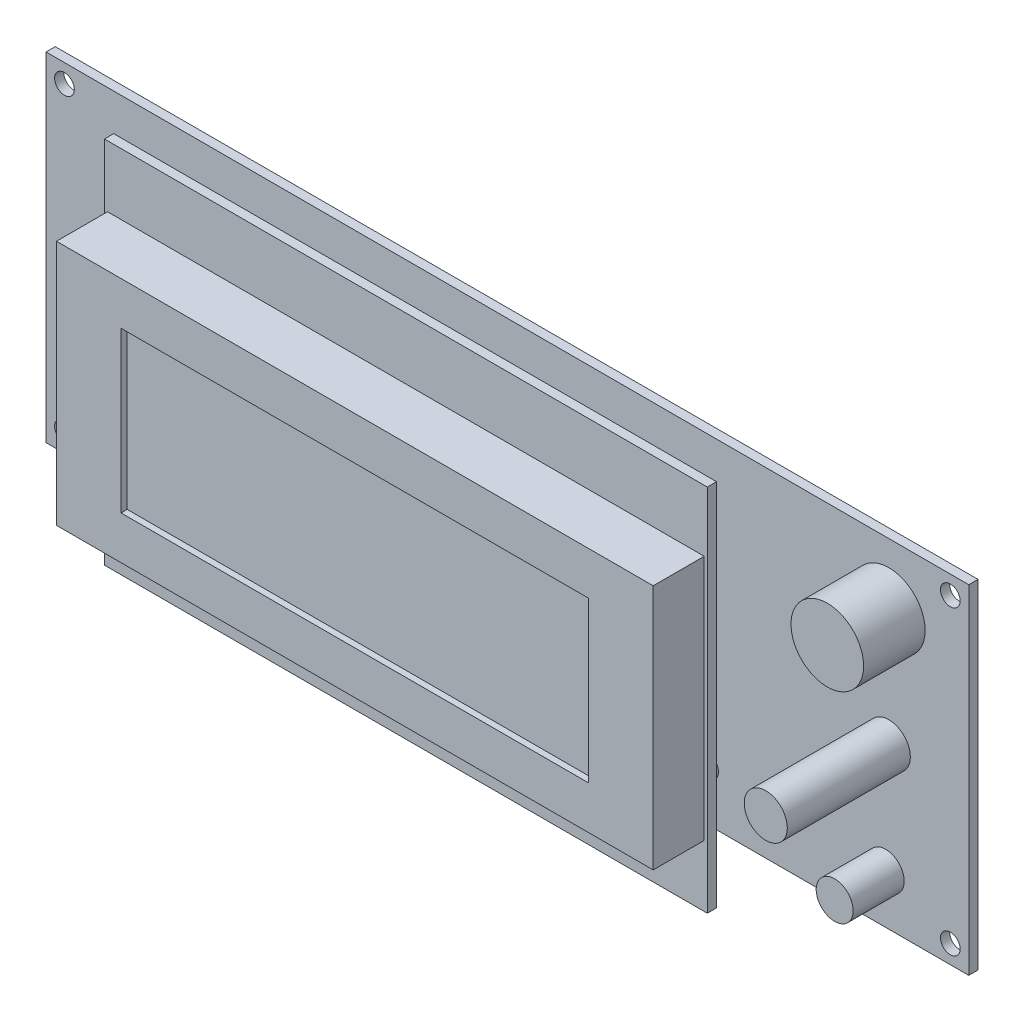
from build123d import *

# Parameters (mm, degrees)
ESBO_O1_W                = 150
ESBO_O1_H                = 55
RESSALTO_EXTRUS_O1_DEPTH = 1.5
RESSALTO_EXTRUS_O2_START = 3
ESBO_O3_W                = 98
ESBO_O3_H                = 60
RESSALTO_EXTRUS_O2_DEPTH = 1.5
ESBO_O4_W                = 97
ESBO_O4_H                = 40
RESSALTO_EXTRUS_O3_DEPTH = 8.3
ESBO_O5_W                = 76
ESBO_O5_H                = 26
CORTE_EXTRUS_O1_DEPTH    = 1
ESBO_O6_R                = 3.5
RESSALTO_EXTRUS_O4_DEPTH = 20
ESBO_O7_R                = 2
RESSALTO_EXTRUS_O5_DEPTH = 4.5
ESBO_O8_R                = 5.9
RESSALTO_EXTRUS_O6_DEPTH = 10
ESBO_O9_R                = 3
RESSALTO_EXTRUS_O7_DEPTH = 8.3
ESBO_O11_W               = 20.3
ESBO_O11_H               = 8.6
RESSALTO_EXTRUS_O8_DEPTH = 15
ESBO_O12_W               = 25.5
ESBO_O12_H               = 26.5
RESSALTO_EXTRUS_O9_DEPTH = 3
ESBO_O13_R               = 1.6
CORTE_EXTRUS_O2_DEPTH    = 10


with BuildPart() as part:
    # Esboço1 → Ressalto-extrusão1 (new body)
    with BuildSketch(Plane.XY):
        Rectangle(ESBO_O1_W, ESBO_O1_H)
    extrude(amount=RESSALTO_EXTRUS_O1_DEPTH)

    # Esboço6 → Ressalto-extrusão4 (add)
    with BuildSketch(Plane.XY.offset(1.5)):
        with Locations((62, -1.5)):
            Circle(ESBO_O6_R)
    extrude(amount=RESSALTO_EXTRUS_O4_DEPTH)

    # Esboço7 → Ressalto-extrusão5 (add)
    with BuildSketch(Plane.XY.offset(1.5)):
        with Locations((32.3, -19.2)):
            Circle(ESBO_O7_R)
    extrude(amount=RESSALTO_EXTRUS_O5_DEPTH)

    # Esboço8 → Ressalto-extrusão6 (add)
    with BuildSketch(Plane.XY.offset(1.5)):
        with Locations((62, 17.5)):
            Circle(ESBO_O8_R)
    extrude(amount=RESSALTO_EXTRUS_O6_DEPTH)

    # Esboço9 → Ressalto-extrusão7 (add)
    with BuildSketch(Plane.XY.offset(1.5)):
        with Locations((61.5, -19.5)):
            Circle(ESBO_O9_R)
    extrude(amount=RESSALTO_EXTRUS_O7_DEPTH)

    # Esboço11 → Ressalto-extrusão8 (add)
    with BuildSketch(Plane(origin=(0, 0, 0), x_dir=(-1, 0, 0), z_dir=(0, 0, -1))):
        with Locations((-13.938731824, 1.2)):
            Rectangle(ESBO_O11_W, ESBO_O11_H)
        with Locations((19.85, 1.2)):
            Rectangle(ESBO_O11_W, ESBO_O11_H)
    extrude(amount=RESSALTO_EXTRUS_O8_DEPTH)

    # Esboço12 → Ressalto-extrusão9 (add)
    with BuildSketch(Plane(origin=(0, 0, 0), x_dir=(-1, 0, 0), z_dir=(0, 0, -1))):
        with Locations((62.15, -7.75)):
            Rectangle(ESBO_O12_W, ESBO_O12_H)
    extrude(amount=RESSALTO_EXTRUS_O9_DEPTH)

    # Esboço13 → Corte-extrusão2 (cut)
    with BuildSketch(Plane.XY.offset(1.5)):
        with Locations((-72, 24.5)):
            Circle(ESBO_O13_R)
        with Locations((-72, -24.5)):
            Circle(ESBO_O13_R)
        with Locations((72, -24.5)):
            Circle(ESBO_O13_R)
        with Locations((72, 24.5)):
            Circle(ESBO_O13_R)
    extrude(amount=-CORTE_EXTRUS_O2_DEPTH, mode=Mode.SUBTRACT)


with BuildPart() as body_2:
    # Esboço3 → Ressalto-extrusão2 (new body)
    with BuildSketch(Plane.XY.offset(1.5).offset(RESSALTO_EXTRUS_O2_START)):
        with Locations((-12, -5.5)):
            Rectangle(ESBO_O3_W, ESBO_O3_H)
    extrude(amount=RESSALTO_EXTRUS_O2_DEPTH)

    # Esboço4 → Ressalto-extrusão3 (add)
    with BuildSketch(Plane.XY.offset(6)):
        with Locations((-12, -5.5)):
            Rectangle(ESBO_O4_W, ESBO_O4_H)
    extrude(amount=RESSALTO_EXTRUS_O3_DEPTH)

    # Esboço5 → Corte-extrusão1 (cut)
    with BuildSketch(Plane.XY.offset(14.3)):
        with Locations((-12, -5.5)):
            Rectangle(ESBO_O5_W, ESBO_O5_H)
    extrude(amount=-CORTE_EXTRUS_O1_DEPTH, mode=Mode.SUBTRACT)


solid = Compound([part.part, body_2.part])
